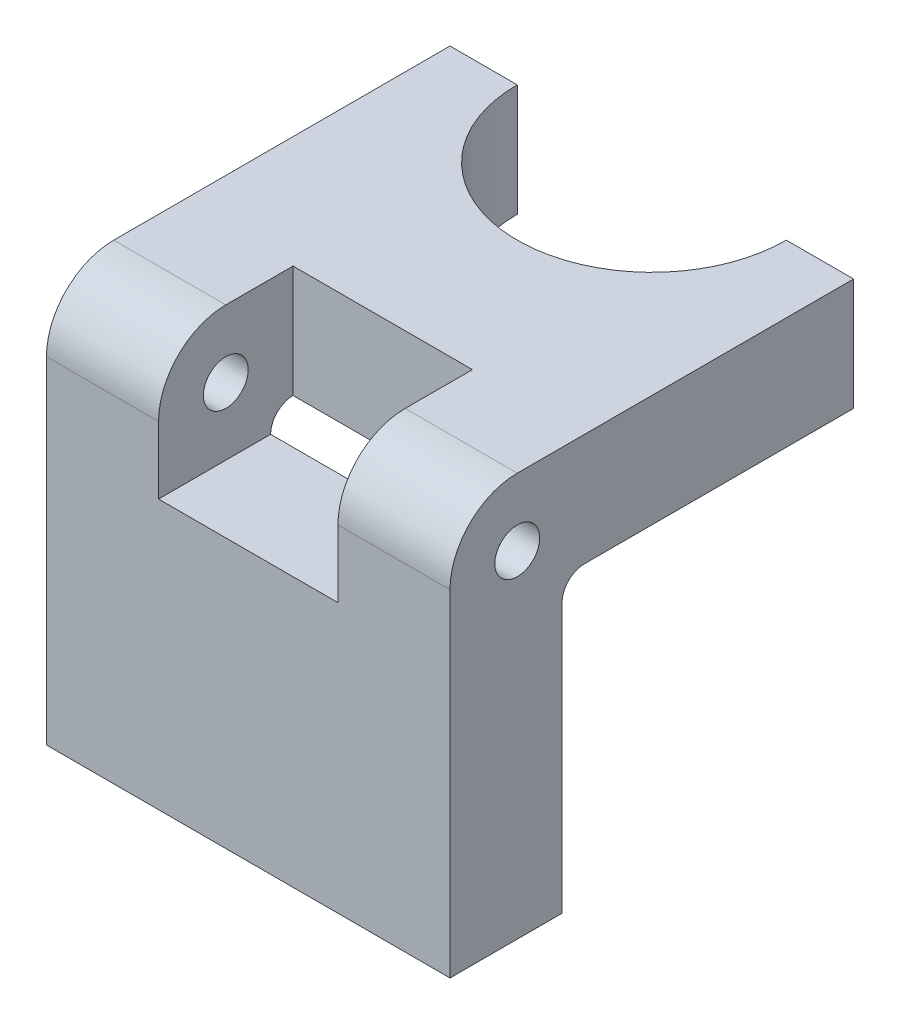
from build123d import *

# Parameters (mm, degrees)
BOSS_EXTRUDE1_DEPTH = 57.15
BOSS_EXTRUDE2_DEPTH = 57.15
CUT_EXTRUDE1_REACH  = 59.15
SKETCH4_R           = 19.05
SKETCH5_R           = 3.175
CUT_EXTRUDE2_DEPTH  = 25.4
SKETCH7_R           = 3.175
CUT_EXTRUDE3_DEPTH  = 58.15


with BuildPart() as part:
    # Sketch2 → Boss-Extrude1 (new body)
    with BuildSketch(Plane(origin=(0, 0, 0), x_dir=(0, 0, -1), z_dir=(1, 0, 0))):
        with BuildLine():
            Line((45.71235962, 13.716504708), (-1.91264038, 13.716504708))
            ThreePointArc((-1.91264038, 13.716504708), (-8.647832471, 10.926696799), (-11.43764038, 4.191504708))
            Line((-11.43764038, 4.191504708), (-11.43764038, -43.433495292))
            Line((-11.43764038, -43.433495292), (4.43735962, -43.433495292))
            Line((4.43735962, -43.433495292), (4.43735962, -2.158495292))
            Line((4.43735962, -2.158495292), (45.71235962, -2.158495292))
            Line((45.71235962, -2.158495292), (45.71235962, 13.716504708))
        make_face()
    extrude(amount=BOSS_EXTRUDE1_DEPTH)

    # Sketch3 → Boss-Extrude2 (add)
    with BuildSketch(Plane(origin=(0, 0, 0), x_dir=(0, 0, -1), z_dir=(1, 0, 0))):
        with BuildLine():
            Line((4.43735962, -5.333495292), (4.43735962, -2.158495292))
            Line((4.43735962, -2.158495292), (7.61235962, -2.158495292))
            ThreePointArc((7.61235962, -2.158495292), (5.36729559, -3.088431262), (4.43735962, -5.333495292))
        make_face()
    extrude(amount=BOSS_EXTRUDE2_DEPTH)

    # Sketch4 → Cut-Extrude1 (cut, up to next)
    with BuildSketch(Plane(origin=(0, 13.716504708, 0), x_dir=(1, 0, 0), z_dir=(0, 1, 0)), mode=Mode.PRIVATE) as cut_extrude1_sk1:
        with Locations((28.575, 45.71235962)):
            Circle(SKETCH4_R)
    cut_extrude1_tool1 = extrude(cut_extrude1_sk1.sketch, amount=-CUT_EXTRUDE1_REACH, mode=Mode.PRIVATE) & part.part
    add(cut_extrude1_tool1.solids().sort_by_distance((28.575, 13.716505, -45.71236))[0], mode=Mode.SUBTRACT)

    # Sketch5 → Cut-Extrude2 (cut)
    with BuildSketch(Plane(origin=(41.275, 0, 0), x_dir=(0, 0, -1), z_dir=(1, 0, 0))):
        with BuildLine():
            Line((7.61235962, -2.158495292), (7.61235962, 13.716504708))
            Line((7.61235962, 13.716504708), (-1.91264038, 13.716504708))
            ThreePointArc((-1.91264038, 13.716504708), (-8.647832471, 10.926696799), (-11.43764038, 4.191504708))
            Line((-11.43764038, 4.191504708), (-11.43764038, -2.158495292))
            Line((-11.43764038, -2.158495292), (-11.43764038, -5.333495292))
            Line((-11.43764038, -5.333495292), (4.43735962, -5.333495292))
            ThreePointArc((4.43735962, -5.333495292), (5.36729559, -3.088431262), (7.61235962, -2.158495292))
        make_face()
        with Locations((-1.91264038, 4.191504708)):
            Circle(SKETCH5_R, mode=Mode.SUBTRACT)
    extrude(amount=-CUT_EXTRUDE2_DEPTH, mode=Mode.SUBTRACT)

    # Sketch7 → Cut-Extrude3 (cut, through all)
    with BuildSketch(Plane(origin=(57.15, 0, 0), x_dir=(0, 0, -1), z_dir=(1, 0, 0))):
        with Locations((-1.91264038, 4.191504708)):
            Circle(SKETCH7_R)
    extrude(amount=-CUT_EXTRUDE3_DEPTH, mode=Mode.SUBTRACT)


solid = part.part
